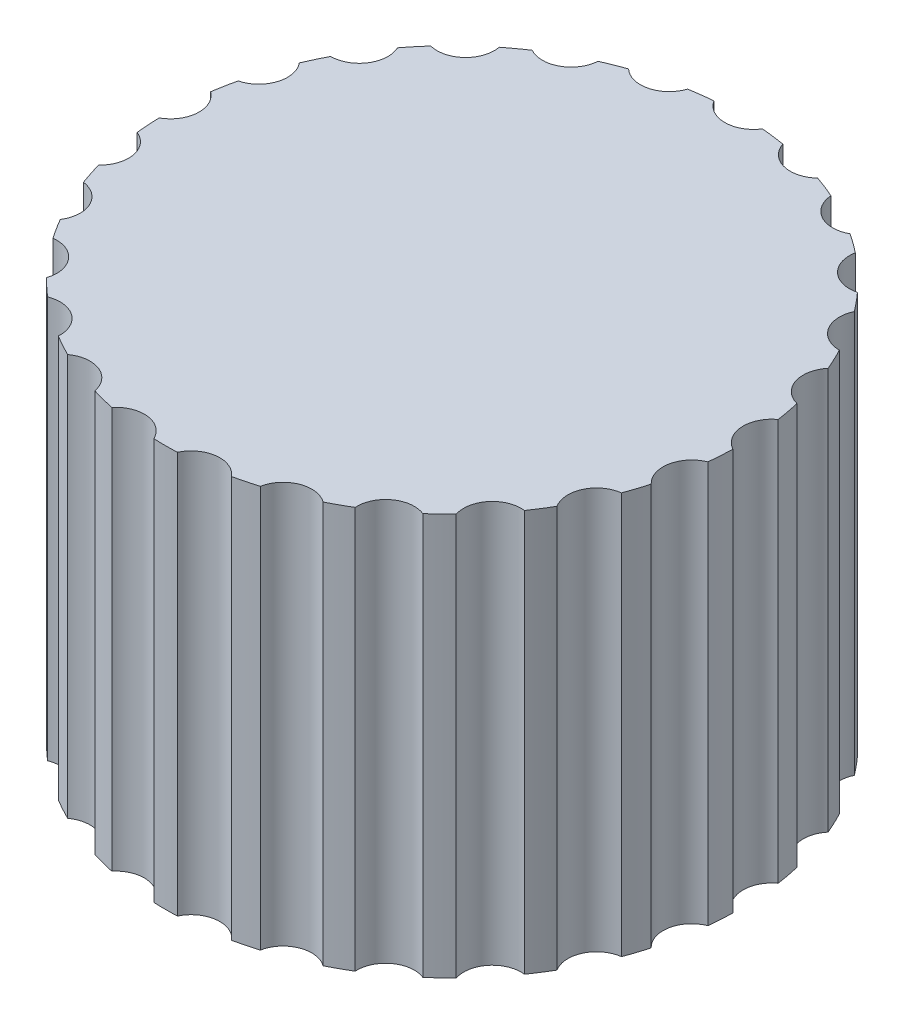
from build123d import *

# Parameters (mm, degrees)
ESQUISSE1_R                  = 10
BOSS_EXTRU_1_DEPTH           = 12
ESQUISSE2_R                  = 10
BOSS_EXTRU_2_DEPTH           = 2
ESQUISSE3_R                  = 1
ENL_V_MAT_EXTRU_1_DEPTH      = 15
R_P_TITION_CIRCULAIRE1_COUNT = 25


with BuildPart() as part:
    # Esquisse1 → Boss.-Extru.1 (new body)
    with BuildSketch(Plane(origin=(0, 0, 0), x_dir=(1, 0, 0), z_dir=(0, 1, 0))):
        Circle(ESQUISSE1_R)
        with BuildLine():
            Line((2.641022529, -1.475), (-2.641022529, -1.475))
            ThreePointArc((-2.641022529, -1.475), (0, 3.025), (2.641022529, -1.475))
        make_face(mode=Mode.SUBTRACT)
    extrude(amount=BOSS_EXTRU_1_DEPTH)

    # Esquisse2 → Boss.-Extru.2 (add)
    with BuildSketch(Plane(origin=(0, 12, 0), x_dir=(1, 0, 0), z_dir=(0, 1, 0))):
        Circle(ESQUISSE2_R)
    extrude(amount=BOSS_EXTRU_2_DEPTH)

    # Esquisse3 → Enlèv. mat.-Extru.1 (cut, through all)
    with BuildSketch(Plane(origin=(0, 14, 0), x_dir=(1, 0, 0), z_dir=(0, 1, 0))):
        with Locations((0, 10.5)):
            Circle(ESQUISSE3_R)
    enl_v_mat_extru_1 = extrude(amount=-ENL_V_MAT_EXTRU_1_DEPTH, mode=Mode.SUBTRACT)

    # Répétition circulaire1: Enlèv. mat.-Extru.1 ×25 about axis
    r_p_tition_circulaire1_axis = Axis((0, 0, 0), (0, 1, 0))
    for i in range(1, R_P_TITION_CIRCULAIRE1_COUNT):
        add(enl_v_mat_extru_1.rotate(r_p_tition_circulaire1_axis, i * 360 / R_P_TITION_CIRCULAIRE1_COUNT), mode=Mode.SUBTRACT)


solid = part.part
